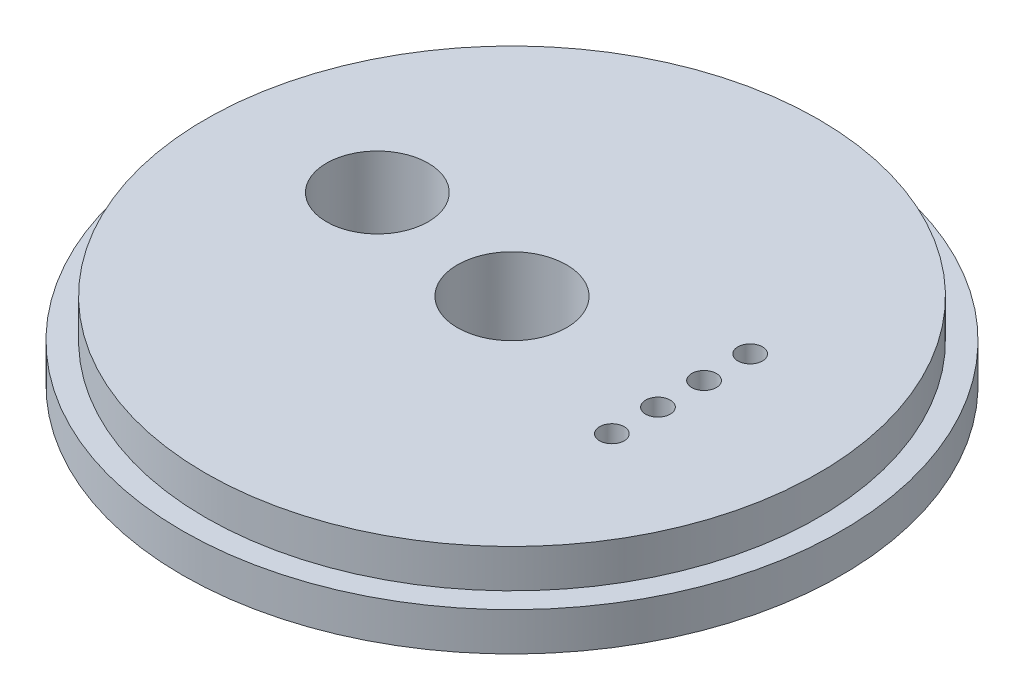
from build123d import *

# Parameters (mm, degrees)
SKETCH1_R           = 27.2415
BOSS_EXTRUDE1_DEPTH = 3.175
SKETCH2_R           = 25.3365
BOSS_EXTRUDE2_DEPTH = 3.175
SKETCH5_R           = 4.2037
CUT_EXTRUDE1_DEPTH  = 6.35
CUT_EXTRUDE2_REACH  = 8.35
SKETCH6_R           = 4.5085
CUT_EXTRUDE3_REACH  = 8.35
SKETCH9_R           = 1.016


with BuildPart() as part:
    # Sketch1 → Boss-Extrude1 (new body)
    with BuildSketch(Plane(origin=(0, 0, 0), x_dir=(1, 0, 0), z_dir=(0, 1, 0))):
        Circle(SKETCH1_R)
    extrude(amount=BOSS_EXTRUDE1_DEPTH)

    # Sketch2 → Boss-Extrude2 (add)
    with BuildSketch(Plane(origin=(0, 3.175, 0), x_dir=(1, 0, 0), z_dir=(0, 1, 0))):
        Circle(SKETCH2_R)
    extrude(amount=BOSS_EXTRUDE2_DEPTH)

    # Sketch5 → Cut-Extrude1 (cut)
    with BuildSketch(Plane.XZ):
        with Locations((-12.992582175, -1.862973623)):
            Circle(SKETCH5_R)
    extrude(amount=-CUT_EXTRUDE1_DEPTH, mode=Mode.SUBTRACT)

    # Sketch6 → Cut-Extrude2 (cut, up to next)
    with BuildSketch(Plane.XZ, mode=Mode.PRIVATE) as cut_extrude2_sk1:
        Circle(SKETCH6_R)
    cut_extrude2_tool1 = extrude(cut_extrude2_sk1.sketch, amount=-CUT_EXTRUDE2_REACH, mode=Mode.PRIVATE) & part.part
    add(cut_extrude2_tool1.solids().sort_by_distance((0, 0, 0))[0], mode=Mode.SUBTRACT)

    # Sketch9 → Cut-Extrude3 (cut, up to next)
    with BuildSketch(Plane(origin=(0, 6.35, 0), x_dir=(1, 0, 0), z_dir=(0, 1, 0)), mode=Mode.PRIVATE) as cut_extrude3_sk1:
        with Locations((13.97, 5.715)):
            Circle(SKETCH9_R)
    cut_extrude3_tool1 = extrude(cut_extrude3_sk1.sketch, amount=-CUT_EXTRUDE3_REACH, mode=Mode.PRIVATE) & part.part
    add(cut_extrude3_tool1.solids().sort_by_distance((13.97, 6.35, -5.715))[0], mode=Mode.SUBTRACT)
    # Sketch9 → Cut-Extrude3 (cut, up to next)
    with BuildSketch(Plane(origin=(0, 6.35, 0), x_dir=(1, 0, 0), z_dir=(0, 1, 0)), mode=Mode.PRIVATE) as cut_extrude3_sk2:
        with Locations((13.97, 1.905)):
            Circle(SKETCH9_R)
    cut_extrude3_tool2 = extrude(cut_extrude3_sk2.sketch, amount=-CUT_EXTRUDE3_REACH, mode=Mode.PRIVATE) & part.part
    add(cut_extrude3_tool2.solids().sort_by_distance((13.97, 6.35, -1.905))[0], mode=Mode.SUBTRACT)
    # Sketch9 → Cut-Extrude3 (cut, up to next)
    with BuildSketch(Plane(origin=(0, 6.35, 0), x_dir=(1, 0, 0), z_dir=(0, 1, 0)), mode=Mode.PRIVATE) as cut_extrude3_sk3:
        with Locations((13.97, -1.905)):
            Circle(SKETCH9_R)
    cut_extrude3_tool3 = extrude(cut_extrude3_sk3.sketch, amount=-CUT_EXTRUDE3_REACH, mode=Mode.PRIVATE) & part.part
    add(cut_extrude3_tool3.solids().sort_by_distance((13.97, 6.35, 1.905))[0], mode=Mode.SUBTRACT)
    # Sketch9 → Cut-Extrude3 (cut, up to next)
    with BuildSketch(Plane(origin=(0, 6.35, 0), x_dir=(1, 0, 0), z_dir=(0, 1, 0)), mode=Mode.PRIVATE) as cut_extrude3_sk4:
        with Locations((13.97, -5.715)):
            Circle(SKETCH9_R)
    cut_extrude3_tool4 = extrude(cut_extrude3_sk4.sketch, amount=-CUT_EXTRUDE3_REACH, mode=Mode.PRIVATE) & part.part
    add(cut_extrude3_tool4.solids().sort_by_distance((13.97, 6.35, 5.715))[0], mode=Mode.SUBTRACT)


solid = part.part
